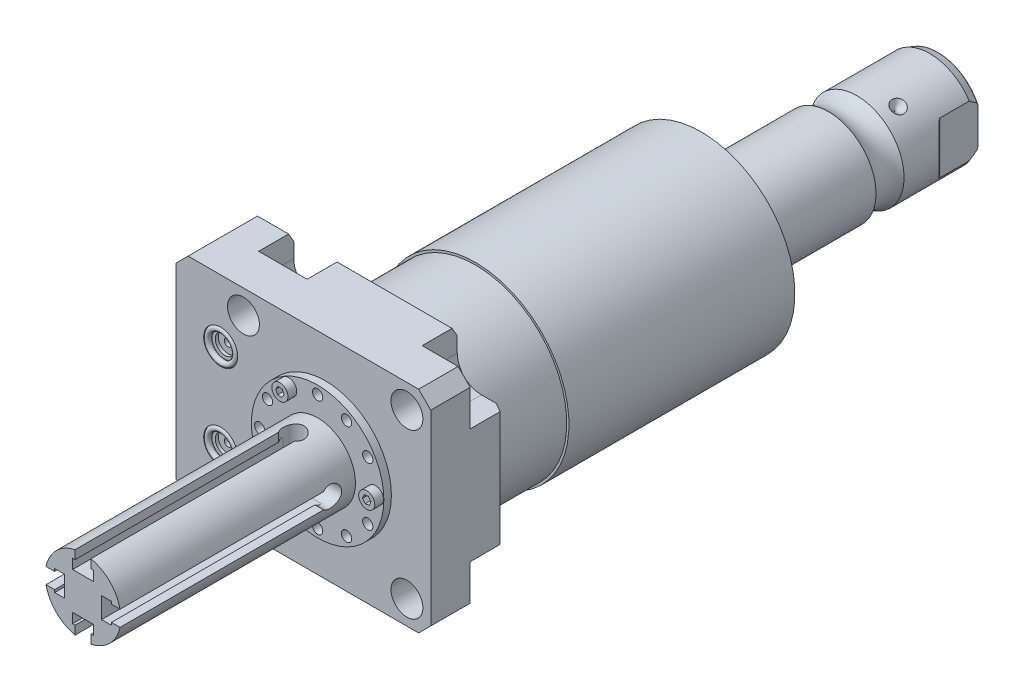
from build123d import *

# Parameters (mm, degrees)
SKETCH1_W                   = 85.4964
SKETCH1_H                   = 70.866
EXTRUDE1_DEPTH              = 25.019
SKETCH2_R                   = 5.3594
CUT_EXTRUDE1_DEPTH          = 27.5209
LPATTERN1_COUNT             = 2
LPATTERN1_PITCH             = 54.864
LPATTERN1_COUNT_DIR2        = 2
LPATTERN1_PITCH_DIR2        = 54.864
CUT_EXTRUDE2_DEPTH          = 11.7856
SKETCH6_R                   = 5.7023
CUT_EXTRUDE3_DEPTH          = 1.4478
SKETCH7_R                   = 3.2512
CUT_EXTRUDE4_DEPTH          = 1.016
SKETCH8_R                   = 1.2446
CUT_EXTRUDE5_DEPTH          = 11.9888
SKETCH9_R                   = 0.9271
CHAMFER1_SIZE               = 4.064
CHAMFER2_SIZE               = 3.0226
CHAMFER2_SIZE2              = 1.745099
SKETCH14_R                  = 31.3944
EXTRUDE2_DEPTH              = 104.5464
SKETCH15_OUTSIDE_W          = 121.686
SKETCH15_OUTSIDE_H          = 107.056
SKETCH15_OUTSIDE_R          = 30.6578
CUT_EXTRUDE9_DEPTH          = 25.4
CIRPATTERN1_COUNT           = 3
FILLET1_R                   = 0.635
CUT_EXTRUDE12_DEPTH         = 36.433
CUT_EXTRUDE12_DEPTH_BACK    = 36.433
SKETCH28_R                  = 1.7272
CUT_EXTRUDE13_DEPTH         = 2.54
SKETCH29_R                  = 2.7051
EXTRUDE3_DEPTH              = 2.9464
CUT_EXTRUDE14_DEPTH         = 2.032
CUT_EXTRUDE15_DEPTH         = 6.477
SKETCH32_W                  = 6.985
SKETCH32_H                  = 70.612
CUT_EXTRUDE16_DEPTH         = 3.302
CIRPATTERN2_COUNT           = 2
CIRPATTERN2_ANGLE           = 90
CIRPATTERN2_COPY_1_DEPTH    = 6.477
CIRPATTERN2_COPY_2_SKETCH_W = 6.985
CIRPATTERN2_COPY_2_SKETCH_H = 70.612
CIRPATTERN2_COPY_2_DEPTH    = 3.302


with BuildPart() as part:
    # Sketch1 → Extrude1 (new body)
    with BuildSketch(Plane.XY):
        with Locations((-7.3152, 0)):
            Rectangle(SKETCH1_W, SKETCH1_H)
    extrude(amount=EXTRUDE1_DEPTH)

    # Sketch2 → Cut-Extrude1 (cut)
    with BuildSketch(Plane(origin=(0, 0, 0), x_dir=(-1, 0, 0), z_dir=(0, 0, -1))):
        with Locations((-27.432, -27.432)):
            Circle(SKETCH2_R)
    cut_extrude1 = extrude(amount=-CUT_EXTRUDE1_DEPTH, mode=Mode.SUBTRACT)

    # LPattern1: Cut-Extrude1 2 × 2
    with Locations(*[(-j * LPATTERN1_PITCH_DIR2, i * LPATTERN1_PITCH, 0) for i in range(LPATTERN1_COUNT) for j in range(LPATTERN1_COUNT_DIR2) if (i, j) != (0, 0)]):
        add(cut_extrude1, mode=Mode.SUBTRACT)

    # Sketch3 → Cut-Extrude2 (cut)
    with BuildSketch(Plane(origin=(0, 0, 0), x_dir=(-1, 0, 0), z_dir=(0, 0, -1))):
        with BuildLine():
            Line((-27.432, -19.304), (-35.433, -19.304))
            Line((-35.433, -19.304), (-35.433, -35.433))
            Line((-35.433, -35.433), (-19.304, -35.433))
            Line((-19.304, -35.433), (-19.304, -27.432))
            ThreePointArc((-19.304, -27.432), (-21.684636, -21.684636), (-27.432, -19.304))
        make_face()
        with BuildLine():
            Line((-35.433, 19.304), (-35.433, 35.433))
            Line((-35.433, 35.433), (-19.304, 35.433))
            Line((-19.304, 35.433), (-19.304, 27.432))
            ThreePointArc((-19.304, 27.432), (-21.684636, 21.684636), (-27.432, 19.304))
            Line((-27.432, 19.304), (-35.433, 19.304))
        make_face()
        with BuildLine():
            Line((19.304, 35.433), (19.304, 27.432))
            ThreePointArc((19.304, 27.432), (27.432, 19.304), (35.56, 27.432))
            Line((35.56, 27.432), (35.56, 35.433))
            Line((35.56, 35.433), (19.304, 35.433))
        make_face()
        with BuildLine():
            Line((35.56, -35.433), (19.304, -35.433))
            Line((19.304, -35.433), (19.304, -27.432))
            ThreePointArc((19.304, -27.432), (27.432, -19.304), (35.56, -27.432))
            Line((35.56, -27.432), (35.56, -35.433))
        make_face()
    extrude(amount=-CUT_EXTRUDE2_DEPTH, mode=Mode.SUBTRACT)

    # S2D0007 → Cut-Revolve1 (revolve, cut)
    with BuildSketch(Plane(origin=(-55.5498, -13.0048, 12.5222), x_dir=(0, 1, 0), z_dir=(0, 0, 1)), mode=Mode.PRIVATE) as cut_revolve1_sk:
        Polygon((0, -5.4864), (10.4775, -5.4864), (10.4775, -5.7404), (6.1849, -5.7404), (5.642307, -8.2931), (4.9784, -8.957007), (4.9784, -19.7104), (0, -19.7104), align=None)
    cut_revolve1 = revolve(cut_revolve1_sk.sketch.rotate(Axis((-35.077219, -13.0048, 12.5222), (-1, 0, 0)), 90), axis=Axis((-35.077219, -13.0048, 12.5222), (-1, 0, 0)), mode=Mode.SUBTRACT)  # turned: the seam where the file's is

    # Mirror1: Cut-Revolve1 across plane
    add(cut_revolve1.mirror(Plane.ZX), mode=Mode.SUBTRACT)

    # Sketch6 → Cut-Extrude3 (cut)
    with BuildSketch(Plane.XY.offset(25.019)):
        with Locations((-35.0774, -14.5288)):
            Circle(SKETCH6_R)
        with Locations((-35.0774, 14.5288)):
            Circle(SKETCH6_R)
    extrude(amount=-CUT_EXTRUDE3_DEPTH, mode=Mode.SUBTRACT)

    # Sketch7 → Cut-Extrude4 (cut)
    with BuildSketch(Plane.XY.offset(23.5712)):
        with Locations((-35.0774, 14.5288)):
            Circle(SKETCH7_R)
        with Locations((-35.0774, -14.5288)):
            Circle(SKETCH7_R)
    extrude(amount=-CUT_EXTRUDE4_DEPTH, mode=Mode.SUBTRACT)

    # Sketch8 → Cut-Extrude5 (cut)
    with BuildSketch(Plane.XY.offset(22.5552)):
        with Locations((-35.0774, 14.5288)):
            Circle(SKETCH8_R)
        with Locations((-35.0774, -14.5288)):
            Circle(SKETCH8_R)
    extrude(amount=-CUT_EXTRUDE5_DEPTH, mode=Mode.SUBTRACT)

    # Chamfer1
    chamfer1_edges = [part.edges().sort_by_distance(p)[0] for p in [
        (-50.0634, 35.433, 12.5095),
        (35.433, 35.433, 18.4023),
        (35.433, -35.433, 18.4023),
        (-50.0634, -35.433, 12.5095),
    ]]
    chamfer(chamfer1_edges, length=CHAMFER1_SIZE)

    # Chamfer2
    chamfer2_edges = [part.edges().sort_by_distance(p)[0] for p in [
        (-40.7797, -35.433, 0),
        (35.433, 0, 0),
        (0, 35.433, 0),
        (-40.7797, 35.433, 0),
        (0, -35.433, 0),
    ]]
    chamfer2_side = [part.faces().sort_by_distance(p)[0] for p in [
        (-8.721449, 0, 0),
    ]]
    chamfer(chamfer2_edges, length=CHAMFER2_SIZE, length2=CHAMFER2_SIZE2, reference=chamfer2_side[0])

    # Sketch14 → Extrude2 (add)
    with BuildSketch(Plane(origin=(0, 0, 0), x_dir=(-1, 0, 0), z_dir=(0, 0, -1))):
        with Locations(Location((0, 0, 0), (0, 0, 140.520961))):  # turned: the seam where the file's is
            Circle(SKETCH14_R)
    extrude(amount=EXTRUDE2_DEPTH)

    # Sketch15 outside → Cut-Extrude9 (cut)
    with BuildSketch(Plane(origin=(0, 0, 0), x_dir=(-1, 0, 0), z_dir=(0, 0, -1))):
        with Locations((7.315, 0)):
            Rectangle(SKETCH15_OUTSIDE_W, SKETCH15_OUTSIDE_H)
        Circle(SKETCH15_OUTSIDE_R, mode=Mode.SUBTRACT)
    extrude(amount=CUT_EXTRUDE9_DEPTH, mode=Mode.SUBTRACT)

    # Sketch16 → Cut-Revolve3 (revolve, cut)
    with BuildSketch(Plane(origin=(0, 0, 0), x_dir=(0, 0, 1), z_dir=(1, 0, 0)), mode=Mode.PRIVATE) as cut_revolve3_sk:
        Polygon((-104.5464, 19.05), (-101.238728, 31.3944), (-104.5464, 31.3944), align=None)
    revolve(cut_revolve3_sk.sketch.rotate(Axis((0, 0, -96.582204), (0, 0, 1)), 270), axis=Axis((0, 0, -96.582204), (0, 0, 1)), mode=Mode.SUBTRACT)  # turned: the seam where the file's is

    # Sketch17 → Revolve3 (revolve)
    with BuildSketch(Plane(origin=(0, 0, 0), x_dir=(0, 0, 1), z_dir=(1, 0, 0)), mode=Mode.PRIVATE) as revolve3_sk:
        with BuildLine():
            Line((-104.5464, 0), (-104.5464, 15.875))
            Line((-104.5464, 15.875), (-143.984506, 15.875))
            ThreePointArc((-143.984506, 15.875), (-148.6916, 14.3256), (-153.398694, 15.875))
            Line((-153.398694, 15.875), (-177.8762, 15.875))
            Line((-177.8762, 15.875), (-180.7972, 14.811843))
            Line((-180.7972, 14.811843), (-180.7972, 0))
            Line((-180.7972, 0), (-104.5464, 0))
        make_face()
    revolve(revolve3_sk.sketch.rotate(Axis((0, 0, -180.9369), (0, 0, 1)), 270), axis=Axis((0, 0, -180.9369), (0, 0, 1)))  # turned: the seam where the file's is

    # Sketch22 → Cut-Revolve4 (revolve, cut)
    with BuildSketch(Plane(origin=(0, 0, 0), x_dir=(1, 0, 0), z_dir=(0, 1, 0)), mode=Mode.PRIVATE) as cut_revolve4_sk:
        Polygon((-15.875, 161.7726), (-15.875, 159.3596), (-13.462, 159.3596), align=None)
    cut_revolve4 = revolve(cut_revolve4_sk.sketch.rotate(Axis((-21.668803, 0, -159.3596), (1, 0, 0)), 180), axis=Axis((-21.668803, 0, -159.3596), (1, 0, 0)), mode=Mode.SUBTRACT)  # turned: the seam where the file's is

    # CirPattern1: Cut-Revolve4 ×3 about axis
    cirpattern1_axis = Axis((0, 0, -180.9369), (0, 0, -1))
    for i in range(1, CIRPATTERN1_COUNT):
        add(cut_revolve4.rotate(cirpattern1_axis, i * 360 / CIRPATTERN1_COUNT), mode=Mode.SUBTRACT)

    # Fillet1
    fillet1_edges = [part.edges().sort_by_distance(p)[0] for p in [
        (14.811843, 0, -180.7972),
    ]]
    fillet(fillet1_edges, radius=FILLET1_R)

    # Sketch24 → Hole1 (revolve, cut)
    with BuildSketch(Plane(origin=(0, 0, -180.7972), x_dir=(0, 1, 0), z_dir=(1, 0, 0))):
        Polygon((0, 0), (0, 25.4), (6.9342, 21.233512), (6.9342, 0), align=None)
    revolve(axis=Axis((0, 0, -185.0414), (0, 0, 1)), mode=Mode.SUBTRACT)

    # Sketch26 → Cut-Extrude12 (cut, two sides)
    with BuildSketch(Plane(origin=(0, 0, 0), x_dir=(1, 0, 0), z_dir=(0, 1, 0))) as cut_extrude12_sk:
        with BuildLine():
            Line((-13.2842, 180.7972), (-13.2842, 168.0972))
            ThreePointArc((-13.2842, 168.0972), (-13.342204, 167.805595), (-13.507385, 167.558385))
            Line((-13.507385, 167.558385), (-15.875, 165.190769))
            Line((-15.875, 165.190769), (-15.875, 180.7972))
            Line((-15.875, 180.7972), (-13.2842, 180.7972))
        make_face()
        with BuildLine():
            Line((15.875, 180.7972), (13.2842, 180.7972))
            Line((13.2842, 180.7972), (13.2842, 168.0972))
            ThreePointArc((13.2842, 168.0972), (13.342204, 167.805595), (13.507385, 167.558385))
            Line((13.507385, 167.558385), (15.875, 165.190769))
            Line((15.875, 165.190769), (15.875, 180.7972))
        make_face()
    extrude(amount=CUT_EXTRUDE12_DEPTH, mode=Mode.SUBTRACT)
    extrude(cut_extrude12_sk.sketch, amount=-CUT_EXTRUDE12_DEPTH_BACK, mode=Mode.SUBTRACT)

    # Sketch27 → Revolve4 (revolve)
    with BuildSketch(Plane(origin=(0, 0, 0), x_dir=(1, 0, 0), z_dir=(0, 1, 0)), mode=Mode.PRIVATE) as revolve4_sk:
        Polygon((22.225, -25.019), (0, -25.019), (0, -106.299), (12.7, -106.299), (12.7, -27.559), (22.225, -27.559), align=None)
    revolve(revolve4_sk.sketch.rotate(Axis((0, 0, 991.574937), (0, 0, -1)), 180), axis=Axis((0, 0, 991.574937), (0, 0, -1)))  # turned: the seam where the file's is

    # Sketch28 → Cut-Extrude13 (cut)
    with BuildSketch(Plane.XY.offset(27.559)):
        with Locations((19.431, 0)):
            Circle(SKETCH28_R)
        with Locations((16.82774, 9.7155)):
            Circle(SKETCH28_R)
        with Locations((9.7155, 16.82774)):
            Circle(SKETCH28_R)
        with Locations((0, 19.431)):
            Circle(SKETCH28_R)
        with Locations(Location((-9.7155, 16.82774, 0), (0, 0, 180))):  # turned: the seam where the file's is
            Circle(SKETCH28_R)
        with Locations(Location((-16.82774, 9.7155, 0), (0, 0, 180))):  # turned: the seam where the file's is
            Circle(SKETCH28_R)
        with Locations(Location((-19.431, 0, 0), (0, 0, 180))):  # turned: the seam where the file's is
            Circle(SKETCH28_R)
        with Locations((-16.82774, -9.7155)):
            Circle(SKETCH28_R)
        with Locations((-9.7155, -16.82774)):
            Circle(SKETCH28_R)
        with Locations(Location((0, -19.431, 0), (0, 0, 180))):  # turned: the seam where the file's is
            Circle(SKETCH28_R)
        with Locations(Location((9.7155, -16.82774, 0), (0, 0, 180))):  # turned: the seam where the file's is
            Circle(SKETCH28_R)
        with Locations(Location((16.82774, -9.7155, 0), (0, 0, 180))):  # turned: the seam where the file's is
            Circle(SKETCH28_R)
    extrude(amount=-CUT_EXTRUDE13_DEPTH, mode=Mode.SUBTRACT)

    # Sketch29 → Extrude3 (add)
    with BuildSketch(Plane.XY.offset(27.559)):
        with Locations((19.431, 0)):
            Circle(SKETCH29_R)
        with Locations((-9.7155, 16.82774)):
            Circle(SKETCH29_R)
        with Locations((-9.7155, -16.82774)):
            Circle(SKETCH29_R)
    extrude(amount=EXTRUDE3_DEPTH)

    # Sketch30 → Cut-Extrude14 (cut)
    with BuildSketch(Plane.XY.offset(30.5054)):
        Polygon((-9.061083, 15.548244), (-8.280215, 16.754734), (-8.934633, 18.03423), (-10.369917, 18.107236), (-11.150785, 16.900746), (-10.496367, 15.62125), align=None)
        Polygon((-9.133395, -18.141713), (-8.286513, -16.980608), (-8.868618, -15.666635), (-10.297605, -15.513766), (-11.144487, -16.674871), (-10.562382, -17.988844), align=None)
        Polygon((20.335319, -1.116951), (20.850467, 0.224688), (19.946148, 1.341639), (18.526681, 1.116951), (18.011533, -0.224688), (18.915852, -1.341639), align=None)
    extrude(amount=-CUT_EXTRUDE14_DEPTH, mode=Mode.SUBTRACT)

    # Sketch31 → Cut-Extrude15 (cut)
    with BuildSketch(Plane(origin=(0, 12.7, 66.929), x_dir=(-1, 0, 0), z_dir=(0, 1, 0))):
        with BuildLine():
            Line((-2.6416, 39.37), (-2.6416, -28.957376))
            ThreePointArc((-2.6416, -28.957376), (0, -34.7345), (2.6416, -28.957376))
            Line((2.6416, -28.957376), (2.6416, 39.37))
            Line((2.6416, 39.37), (-2.6416, 39.37))
        make_face()
    cut_extrude15 = extrude(amount=-CUT_EXTRUDE15_DEPTH, mode=Mode.SUBTRACT)

    # Sketch32 → Cut-Extrude16 (cut)
    with BuildSketch(Plane(origin=(0, 6.223, 0), x_dir=(1, 0, 0), z_dir=(0, 1, 0))):
        with Locations((0, -70.993)):
            Rectangle(SKETCH32_W, SKETCH32_H)
    cut_extrude16 = extrude(amount=CUT_EXTRUDE16_DEPTH, mode=Mode.SUBTRACT)

    # Mirror3: Cut-Extrude15, Cut-Extrude16 across plane
    add(cut_extrude15.mirror(Plane.ZX), mode=Mode.SUBTRACT)
    add(cut_extrude16.mirror(Plane.ZX), mode=Mode.SUBTRACT)

    # CirPattern2: Cut-Extrude15, Cut-Extrude16 ×2 about axis
    cirpattern2_axis = Axis((0, 0, 0), (0, 0, 1))
    add([cut_extrude15.rotate(cirpattern2_axis, i * CIRPATTERN2_ANGLE / (CIRPATTERN2_COUNT - 1)) for i in range(1, CIRPATTERN2_COUNT)], mode=Mode.SUBTRACT)
    add([cut_extrude16.rotate(cirpattern2_axis, i * CIRPATTERN2_ANGLE / (CIRPATTERN2_COUNT - 1)) for i in range(1, CIRPATTERN2_COUNT)], mode=Mode.SUBTRACT)

    # CirPattern2 copy 1 sketch → CirPattern2 copy 1 (cut)
    with BuildSketch(Plane(origin=(12.7, 0, 66.929), x_dir=(0, -1, 0), z_dir=(1, 0, 0))):
        with BuildLine():
            Line((-2.6416, -39.37), (-2.6416, 28.957376))
            ThreePointArc((-2.6416, 28.957376), (0, 34.7345), (2.6416, 28.957376))
            Line((2.6416, 28.957376), (2.6416, -39.37))
            Line((2.6416, -39.37), (-2.6416, -39.37))
        make_face()
    extrude(amount=-CIRPATTERN2_COPY_1_DEPTH, mode=Mode.SUBTRACT)

    # CirPattern2 copy 2 sketch → CirPattern2 copy 2 (cut)
    with BuildSketch(Plane.YZ.offset(6.223)):
        with Locations((0, 70.993)):
            Rectangle(CIRPATTERN2_COPY_2_SKETCH_W, CIRPATTERN2_COPY_2_SKETCH_H)
    extrude(amount=CIRPATTERN2_COPY_2_DEPTH, mode=Mode.SUBTRACT)


with BuildPart() as body_2:
    # Sketch9 → Revolve1 (revolve)
    with BuildSketch(Plane(origin=(-41.656, -14.5288, 23.5712), x_dir=(1, 0, 0), z_dir=(0, 1, 0))):
        with Locations((11.3538, -0.9271)):
            Circle(SKETCH9_R)
    revolve(axis=Axis((-35.0774, -14.5288, 25.51811), (0, 0, -1)))


with BuildPart() as body_3:
    # Mirror2: mirrored copy
    add(body_2.part.mirror(Plane.ZX))


solid = Compound([part.part, body_2.part, body_3.part])
